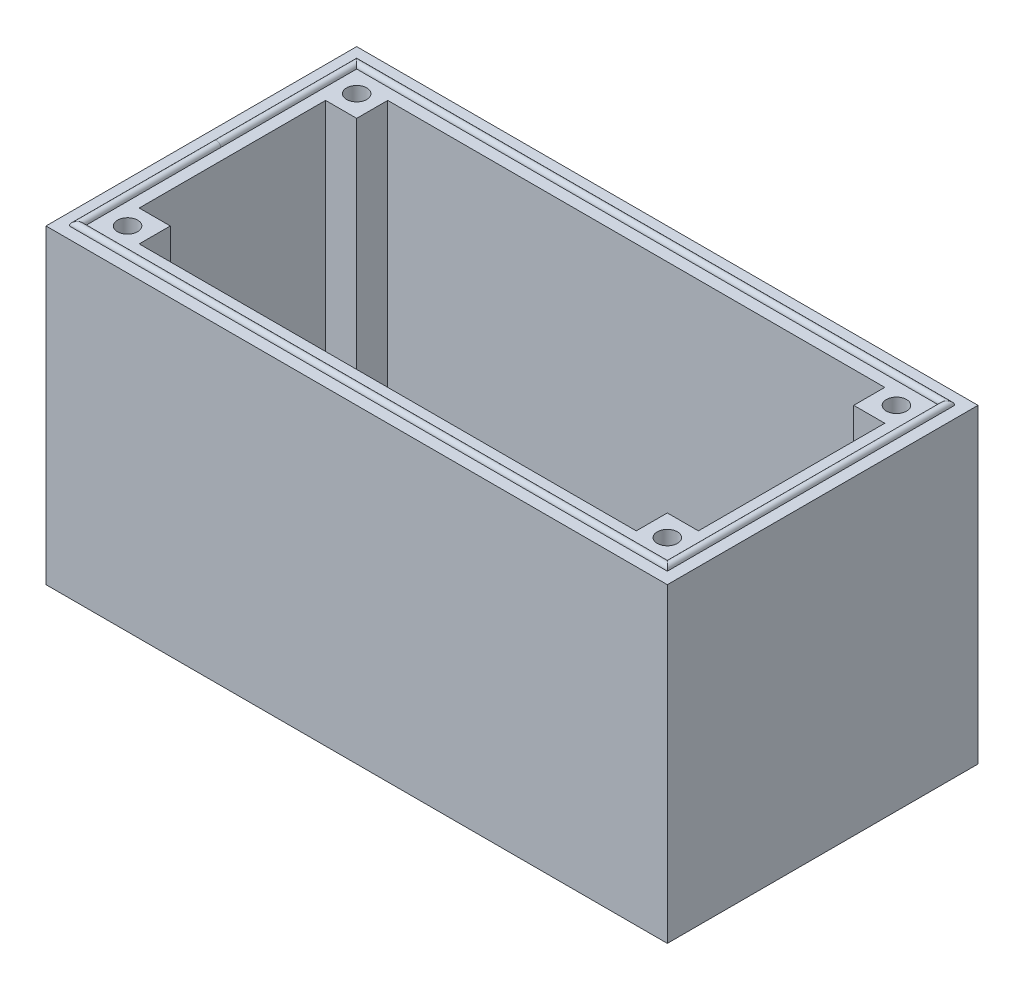
from build123d import *

# Parameters (mm, degrees)
SCHIZZO1_W                     = 40
SCHIZZO1_H                     = 20
ESTRUSIONE_ESTRUSIONE1_DEPTH   = 20
TAGLIO_ESTRUSIONE1_DEPTH       = 20
FORO_PER_VITE_M1_1_D           = 1.3
FORO_PER_VITE_M1_1_CSINK_D     = 1.35
FORO_PER_VITE_M1_1_CSINK_ANGLE = 90
SPECCHIA2_COPY_1_D             = 1.3
SPECCHIA2_COPY_1_CSINK_D       = 1.35
SPECCHIA2_COPY_1_CSINK_ANGLE   = 90


with BuildPart() as part:
    # Schizzo1 → Estrusione-Estrusione1 (new body)
    with BuildSketch(Plane.XY):
        with Locations((20, 10)):
            Rectangle(SCHIZZO1_W, SCHIZZO1_H)
    extrude(amount=-ESTRUSIONE_ESTRUSIONE1_DEPTH)

    # Schizzo2 → Taglio-Estrusione1 (cut)
    with BuildSketch(Plane(origin=(0, 20, 0), x_dir=(1, 0, 0), z_dir=(0, 1, 0))):
        Polygon((4, 18), (4, 16), (2, 16), (2, 4), (4, 4), (4, 2), (36, 2), (36, 4), (38, 4), (38, 16), (36, 16), (36, 18), align=None)
    extrude(amount=-TAGLIO_ESTRUSIONE1_DEPTH, mode=Mode.SUBTRACT)

    # Sweep1: sweep along a path in Schizzo4
    with BuildLine(Plane(origin=(0, 20, 0), x_dir=(1, 0, 0), z_dir=(0, 1, 0))) as sweep1_path:
        Line((1, 19), (39, 19))
        Line((39, 19), (39, 1))
        Line((39, 1), (1, 1))
        Line((1, 1), (1, 19))
    # Schizzo3 → Sweep1 (sweep)
    with BuildSketch(Plane.XY.offset(-10)):
        with BuildLine():
            Line((0.75, 20), (1.25, 20))
            ThreePointArc((1.25, 20), (1, 20.25), (0.75, 20))
        make_face()
    sweep(path=sweep1_path.line, transition=Transition.RIGHT)

    # Taglia-Sweep1: sweep along a path in Schizzo5
    with BuildLine(Plane.XZ) as taglia_sweep1_path:
        Line((1, -19), (39, -19))
        Line((39, -19), (39, -1))
        Line((39, -1), (1, -1))
        Line((1, -1), (1, -19))
    # Schizzo6 → Taglia-Sweep1 (sweep, cut)
    with BuildSketch(Plane.XY.offset(-10)):
        with BuildLine():
            Line((0.75, 0), (1.25, 0))
            ThreePointArc((1.25, 0), (1, 0.25), (0.75, 0))
        make_face()
    sweep(path=taglia_sweep1_path.line, transition=Transition.RIGHT, mode=Mode.SUBTRACT)

    # Foro per Vite M1-1 (through all)
    with Locations(Plane(origin=(0, 0, 0), x_dir=(-1, 0, 0), z_dir=(0, -1, 0))):
        with Locations((-37.375, 17.375)):
            foro_per_vite_m1_1 = CounterSinkHole(FORO_PER_VITE_M1_1_D / 2, FORO_PER_VITE_M1_1_CSINK_D / 2, counter_sink_angle=FORO_PER_VITE_M1_1_CSINK_ANGLE)

    # Specchia1: Foro per Vite M1-1 across plane
    add(foro_per_vite_m1_1.mirror(Plane.XY.offset(-10)), mode=Mode.SUBTRACT)

    # Specchia2: Foro per Vite M1-1 across plane
    add(foro_per_vite_m1_1.mirror(Plane(origin=(20, 0, 0), x_dir=(0, 0, 1), z_dir=(1, 0, 0))), mode=Mode.SUBTRACT)

    # Specchia2 copy 1 (through all)
    with Locations(Plane(origin=(40, 0, -20), x_dir=(1, 0, 0), z_dir=(0, -1, 0))):
        with Locations((-37.375, 17.375)):
            CounterSinkHole(SPECCHIA2_COPY_1_D / 2, SPECCHIA2_COPY_1_CSINK_D / 2, counter_sink_angle=SPECCHIA2_COPY_1_CSINK_ANGLE)


solid = part.part
